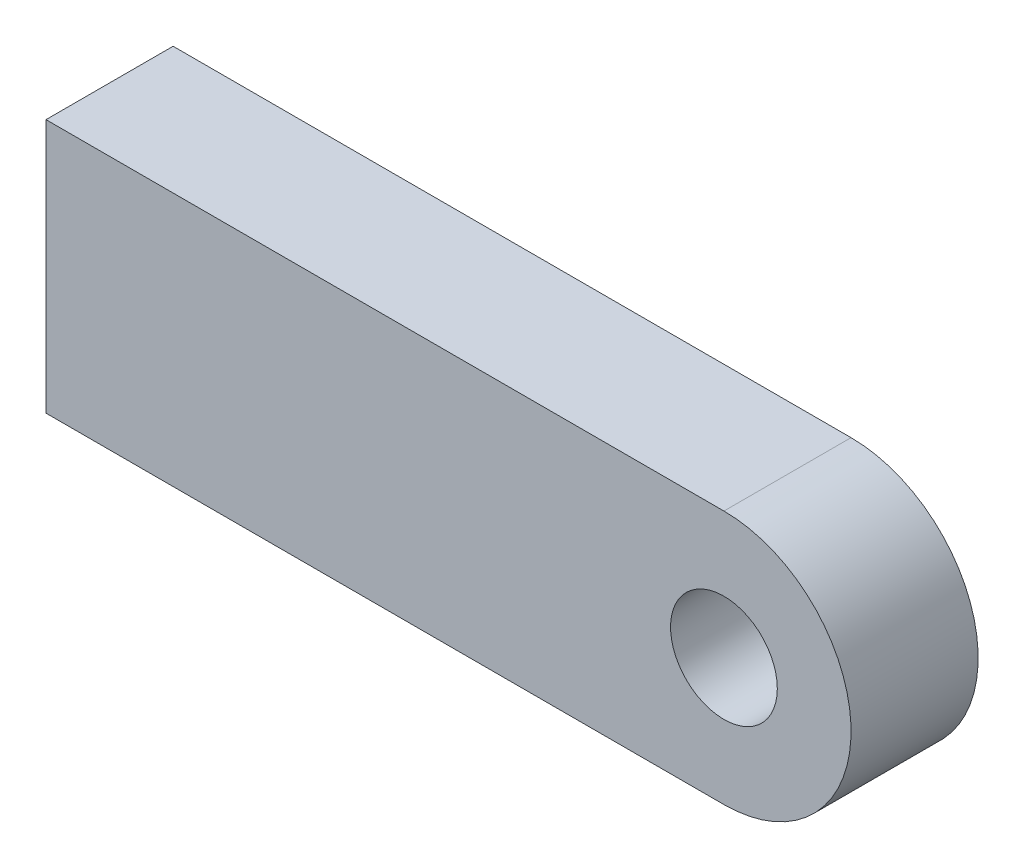
from build123d import *

# Parameters (mm, degrees)
BOSS_EXTRUDE1_DEPTH      = 4.7625
BOSS_EXTRUDE1_DEPTH_BACK = 4.7625


with BuildPart() as part:
    # Sketch1 → Boss-Extrude1 (new, two sides: drawn at the far end of the back side and taken through both)
    with BuildSketch(Plane.XY.offset(1568.073662845).offset(-BOSS_EXTRUDE1_DEPTH_BACK)):
        with BuildLine():
            Line((175.980244033, 626.72659627), (175.980244033, 617.20159627))
            Line((175.980244033, 617.20159627), (175.980244033, 607.67659627))
            Line((175.980244033, 607.67659627), (226.780244033, 607.67659627))
            ThreePointArc((226.780244033, 607.67659627), (236.305244033, 617.20159627), (226.780244033, 626.72659627))
            Line((226.780244033, 626.72659627), (175.980244033, 626.72659627))
        make_face()
        with BuildLine():
            ThreePointArc((230.780244033, 617.20159627), (226.780244033, 613.20159627), (222.780244033, 617.20159627))
            ThreePointArc((222.780244033, 617.20159627), (226.780244033, 621.20159627), (230.780244033, 617.20159627))
        make_face(mode=Mode.SUBTRACT)
    extrude(amount=BOSS_EXTRUDE1_DEPTH + BOSS_EXTRUDE1_DEPTH_BACK)


solid = part.part
